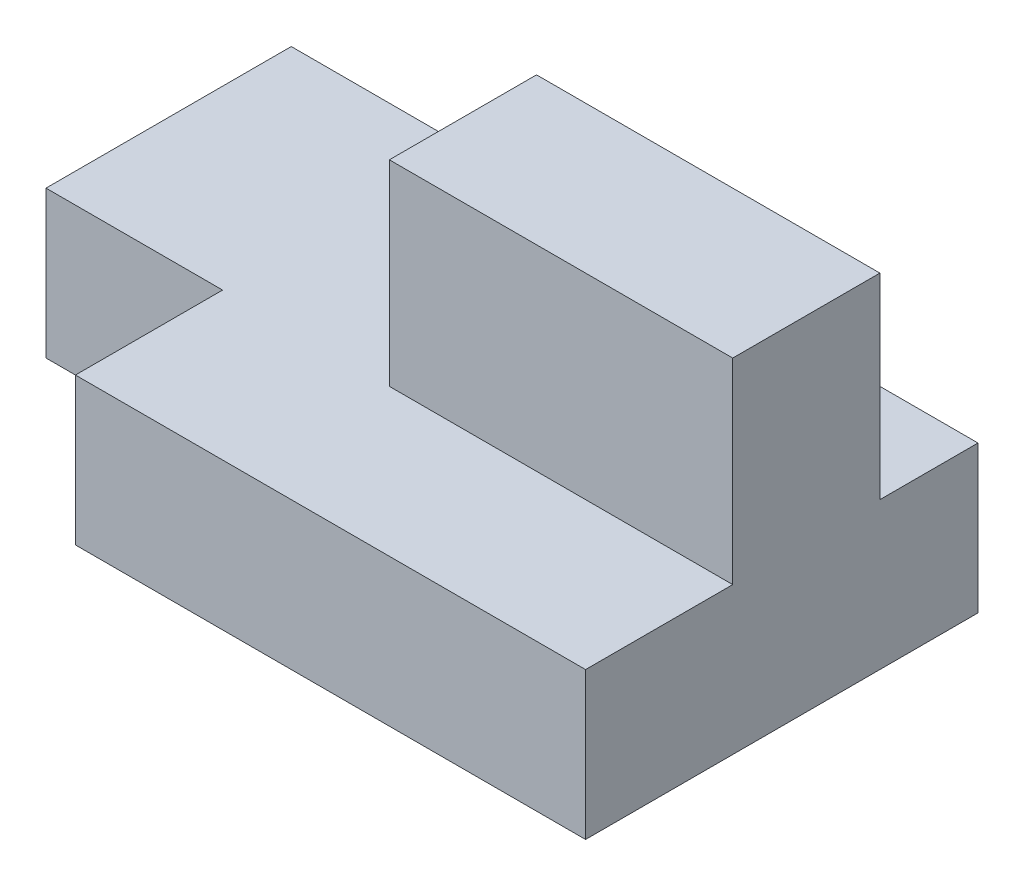
from build123d import *

# Parameters (mm, degrees)
BOSS_EXTRUDE1_DEPTH = 15
SKETCH2_W           = 35
SKETCH2_H           = 15
BOSS_EXTRUDE2_DEPTH = 20


with BuildPart() as part:
    # Sketch1 → Boss-Extrude1 (new body)
    with BuildSketch(Plane(origin=(0, 0, 0), x_dir=(1, 0, 0), z_dir=(0, 1, 0))):
        Polygon((0, 0), (-70, 0), (-70, -25), (-52, -25), (-52, -40), (0, -40), align=None)
    extrude(amount=BOSS_EXTRUDE1_DEPTH)

    # Sketch2 → Boss-Extrude2 (add)
    with BuildSketch(Plane(origin=(0, 15, 0), x_dir=(1, 0, 0), z_dir=(0, 1, 0))):
        with Locations((-17.5, -17.5)):
            Rectangle(SKETCH2_W, SKETCH2_H)
    extrude(amount=BOSS_EXTRUDE2_DEPTH)


solid = part.part
